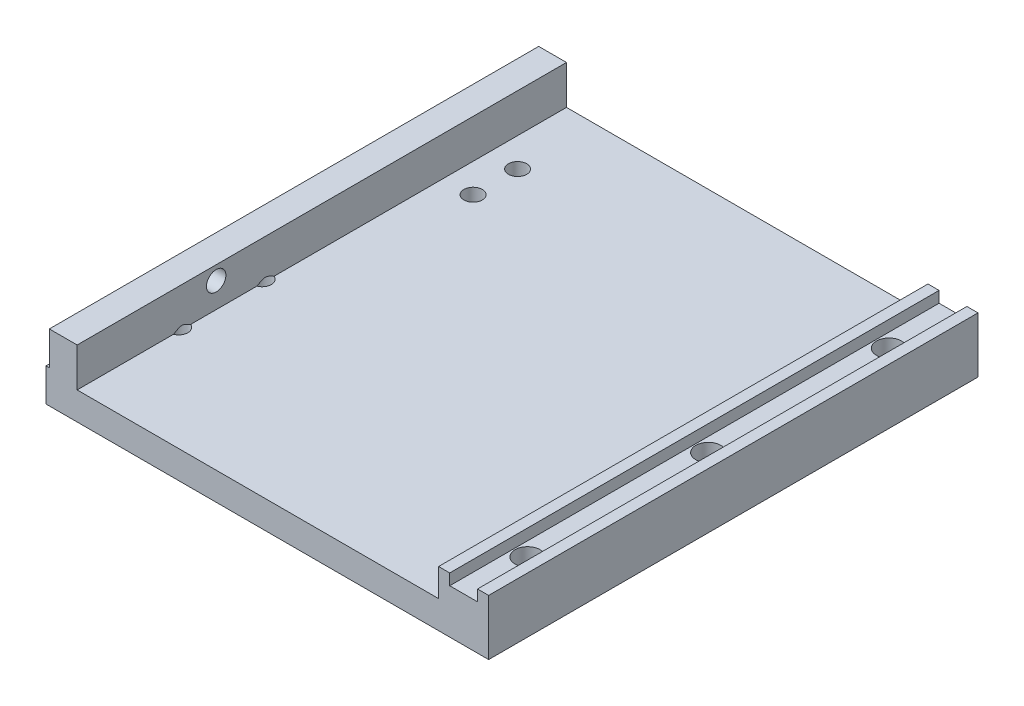
from build123d import *

# Parameters (mm, degrees)
EXTRUDE_1_DEPTH              = 88
HOLE_WIZARD_M4_1_D           = 4.5
HOLE_WIZARD_M4_1_CBORE_D     = 8
HOLE_WIZARD_M4_1_CBORE_DEPTH = 4.4
HOLE_WIZARD_M4_1_2_D         = 3.3
HOLE_WIZARD_M3_1_D           = 2.5
HOLE_WIZARD_M3_1_DEPTH       = 9.5
HOLE_WIZARD_M3_1_TIP         = 0.751075774
SKETCH_8_R                   = 1.75
CUT_EXTRUDE_1_DEPTH          = 5
SKETCH_9_W                   = 0.6
SKETCH_9_H                   = 88
EXTRUDE_2_DEPTH              = 0.05
HOLE_WIZARD_M4_2_D           = 3.3
HOLE_WIZARD_M4_2_DEPTH       = 5
HOLE_WIZARD_M4_2_TIP         = 0.991420021


with BuildPart() as part:
    # 草图1 → 凸台-拉伸1 (new body)
    with BuildSketch(Plane.XY):
        Polygon((-9, 10), (-9, 5), (-74, 5), (-74, 12), (-79, 12), (-79, 5.9), (-79.6, 5.9), (-79.6, 0), (0, 0), (0, 10), (-2, 10), (-2, 8), (-7, 8), (-7, 10), align=None)
    extrude(amount=EXTRUDE_1_DEPTH)

    # Hole Wizard M4 _1 (through all)
    with Locations(Plane(origin=(0, 0, 0), x_dir=(-1, 0, 0), z_dir=(0, -1, 0))):
        with Locations((4.5, -11.5), (4.5, -44), (4.5, -76.5)):
            CounterBoreHole(HOLE_WIZARD_M4_1_D / 2, HOLE_WIZARD_M4_1_CBORE_D / 2, HOLE_WIZARD_M4_1_CBORE_DEPTH)

    # Hole Wizard M4 _1 2 (through all)
    with Locations(Plane(origin=(0, 0, 0), x_dir=(-1, 0, 0), z_dir=(0, -1, 0))):
        with Locations((68.8, -14), (68.8, -22)):
            Hole(HOLE_WIZARD_M4_1_2_D / 2)

    # M3 螺纹孔1
    with Locations(Plane.ZY.offset(79.6)):
        with Locations((11.5, 3), (44, 3), (76.5, 3)):
            Hole(HOLE_WIZARD_M3_1_D / 2, depth=HOLE_WIZARD_M3_1_DEPTH)
            with Locations((0, 0, -(HOLE_WIZARD_M3_1_DEPTH + HOLE_WIZARD_M3_1_TIP / 2))):  # 118° drill point
                Cone(0, HOLE_WIZARD_M3_1_D / 2, HOLE_WIZARD_M3_1_TIP, mode=Mode.SUBTRACT)

    # 草图8 → 切除-拉伸1 (cut)
    with BuildSketch(Plane.ZY.offset(79)):
        with Locations((63, 9.5)):
            Circle(SKETCH_8_R)
    extrude(amount=-CUT_EXTRUDE_1_DEPTH, mode=Mode.SUBTRACT)

    # 草图9 → 凸台-拉伸2 (add)
    with BuildSketch(Plane(origin=(0, 5.9, 0), x_dir=(1, 0, 0), z_dir=(0, 1, 0))):
        with Locations((-79.3, -44)):
            Rectangle(SKETCH_9_W, SKETCH_9_H)
    extrude(amount=EXTRUDE_2_DEPTH)

    # M4 螺纹孔2
    with Locations(Plane(origin=(0, 0, 0), x_dir=(-1, 0, 0), z_dir=(0, -1, 0))):
        with Locations((74.6, -54.141815628), (74.6, -69.141815628)):
            Hole(HOLE_WIZARD_M4_2_D / 2, depth=HOLE_WIZARD_M4_2_DEPTH)
            with Locations((0, 0, -(HOLE_WIZARD_M4_2_DEPTH + HOLE_WIZARD_M4_2_TIP / 2))):  # 118° drill point
                Cone(0, HOLE_WIZARD_M4_2_D / 2, HOLE_WIZARD_M4_2_TIP, mode=Mode.SUBTRACT)


solid = part.part
